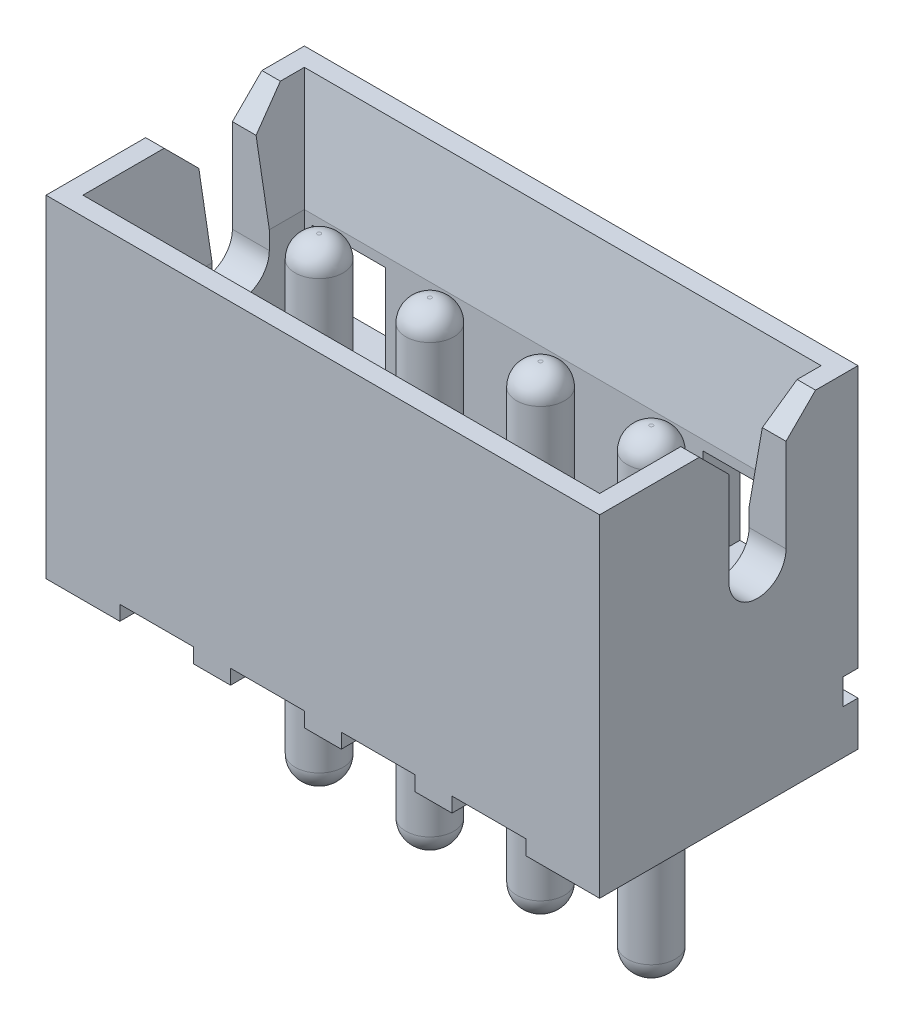
from build123d import *

# Parameters (mm, degrees)
SKETCH_1_W                     = 7.5
SKETCH_1_H                     = 3.5
SKETCH_1_R                     = 0.325
EXTRUDE_1_DEPTH                = 4.5
SKETCH_2_W                     = 6.5
SKETCH_2_H                     = 2.5
CUT_EXTRUDE_1_DEPTH            = 4
SKETCH_3_W                     = 7
SKETCH_3_H                     = 3
CUT_EXTRUDE_2_DEPTH            = 2
CUT_EXTRUDE_2_TAPER            = 10
SKETCH_4_W                     = 7.5
SKETCH_4_H                     = 0.35
CUT_EXTRUDE_3_DEPTH            = 0.2
SKETCH_5_W                     = 1
SKETCH_5_H                     = 3.5
CUT_EXTRUDE_4_DEPTH            = 0.2
PATTERN_LINEAR_2_COUNT         = 4
PATTERN_LINEAR_2_PITCH         = 1.5
SKETCH_6_W                     = 1
SKETCH_6_H                     = 1.3
CUT_EXTRUDE_5_DEPTH            = 0.5
CUT_EXTRUDE_6_DEPTH            = 8.5
CHAMFER_1_SIZE                 = 0.4
EXTRUDE_START                  = -3.7
SKETCH_8_R                     = 0.325
EXTRUDE_2_DEPTH                = 6.4
FILLET_1_R                     = 0.3
PATTERN_LINEAR_3_COUNT         = 4
PATTERN_LINEAR_3_PITCH         = 1.5
FILLET_1_OF_PATTERN_LINEAR_3_R = 0.3


with BuildPart() as part:
    # Эскиз1 → Бобышка-Вытянуть1 (new body)
    with BuildSketch(Plane(origin=(0, 0, 0), x_dir=(1, 0, 0), z_dir=(0, 1, 0))):
        Rectangle(SKETCH_1_W, SKETCH_1_H)
        with Locations((2.25, 0.45)):
            Circle(SKETCH_1_R, mode=Mode.SUBTRACT)
        with Locations((0.75, 0.45)):
            Circle(SKETCH_1_R, mode=Mode.SUBTRACT)
        with Locations((-0.75, 0.45)):
            Circle(SKETCH_1_R, mode=Mode.SUBTRACT)
        with Locations((-2.25, 0.45)):
            Circle(SKETCH_1_R, mode=Mode.SUBTRACT)
    extrude(amount=EXTRUDE_1_DEPTH)

    # Эскиз2 → Вырез-Вытянуть1 (cut)
    with BuildSketch(Plane(origin=(0, 4.5, 0), x_dir=(1, 0, 0), z_dir=(0, 1, 0))):
        Rectangle(SKETCH_2_W, SKETCH_2_H)
    extrude(amount=-CUT_EXTRUDE_1_DEPTH, mode=Mode.SUBTRACT)

    # Эскиз3 → Вырез-Вытянуть2 (cut)
    with BuildSketch(Plane(origin=(0, 4.5, 0), x_dir=(1, 0, 0), z_dir=(0, 1, 0))):
        Rectangle(SKETCH_3_W, SKETCH_3_H)
    extrude(amount=-CUT_EXTRUDE_2_DEPTH, taper=CUT_EXTRUDE_2_TAPER, mode=Mode.SUBTRACT)

    # Эскиз4 → Вырез-Вытянуть3 (cut)
    with BuildSketch(Plane(origin=(0, 0, -1.75), x_dir=(-1, 0, 0), z_dir=(0, 0, -1))):
        with Locations((0, 0.775)):
            Rectangle(SKETCH_4_W, SKETCH_4_H)
    extrude(amount=-CUT_EXTRUDE_3_DEPTH, mode=Mode.SUBTRACT)

    # Эскиз5 → Вырез-Вытянуть4 (cut)
    with BuildSketch(Plane.XZ):
        with Locations((2.25, 0)):
            Rectangle(SKETCH_5_W, SKETCH_5_H)
    cut_extrude_4 = extrude(amount=-CUT_EXTRUDE_4_DEPTH, mode=Mode.SUBTRACT)

    # Линейный массив2: Вырез-Вытянуть4 ×4
    with Locations(*[(-i * PATTERN_LINEAR_2_PITCH, 0, 0) for i in range(1, PATTERN_LINEAR_2_COUNT)]):
        add(cut_extrude_4, mode=Mode.SUBTRACT)

    # Эскиз6 → Вырез-Вытянуть5 (cut)
    with BuildSketch(Plane(origin=(0, 0, -1.75), x_dir=(-1, 0, 0), z_dir=(0, 0, -1))):
        with Locations((-2.65, 2.3)):
            Rectangle(SKETCH_6_W, SKETCH_6_H)
    cut_extrude_5 = extrude(amount=-CUT_EXTRUDE_5_DEPTH, mode=Mode.SUBTRACT)

    # Зеркальное отражение1: Вырез-Вытянуть5 across plane
    add(cut_extrude_5.mirror(Plane(origin=(0, 0, 0), x_dir=(0, 0, 1), z_dir=(1, 0, 0))), mode=Mode.SUBTRACT)

    # Эскиз7 → Вырез-Вытянуть6 (cut, through all)
    with BuildSketch(Plane.ZY.offset(3.75)):
        with BuildLine():
            Line((0, 4.5), (0, 2.837933865))
            ThreePointArc((0, 2.837933865), (-0.3875, 2.450433865), (-0.775, 2.837933865))
            Line((-0.775, 2.837933865), (-0.775, 4.5))
            Line((-0.775, 4.5), (0, 4.5))
        make_face()
    extrude(amount=-CUT_EXTRUDE_6_DEPTH, mode=Mode.SUBTRACT)

    # Фаска1
    chamfer_1_edges = [part.edges().sort_by_distance(p)[0] for p in [
        (-3.625, 4.5, -0.775),
        (3.625, 4.5, -0.775),
        (-3.625, 4.5, 0),
        (3.625, 4.5, 0),
    ]]
    chamfer(chamfer_1_edges, length=CHAMFER_1_SIZE)

    # Эскиз8 → Бобышка-Вытянуть2 (add)
    with BuildSketch(Plane.XZ.offset(EXTRUDE_START)):
        with Locations((2.25, -0.45)):
            Circle(SKETCH_8_R)
    extrude_2 = extrude(amount=EXTRUDE_2_DEPTH)

    # Скругление1
    fillet_1_edges = [part.edges().sort_by_distance(p)[0] for p in [
        (1.925, 3.7, -0.45),
        (1.925, -2.7, -0.45),
    ]]
    fillet(fillet_1_edges, radius=FILLET_1_R)

    # Линейный массив3: Бобышка-Вытянуть2 ×4
    with Locations(*[(-i * PATTERN_LINEAR_3_PITCH, 0, 0) for i in range(1, PATTERN_LINEAR_3_COUNT)]):
        add(extrude_2)

    # Скругление1 of Линейный массив3
    fillet_1_of_pattern_linear_3_edges = [part.edges().sort_by_distance(p)[0] for p in [
        (0.425, 3.7, -0.45),
        (0.425, -2.7, -0.45),
        (-1.075, 3.7, -0.45),
        (-1.075, -2.7, -0.45),
        (-2.575, 3.7, -0.45),
        (-2.575, -2.7, -0.45),
    ]]
    fillet(fillet_1_of_pattern_linear_3_edges, radius=FILLET_1_OF_PATTERN_LINEAR_3_R)


solid = part.part
